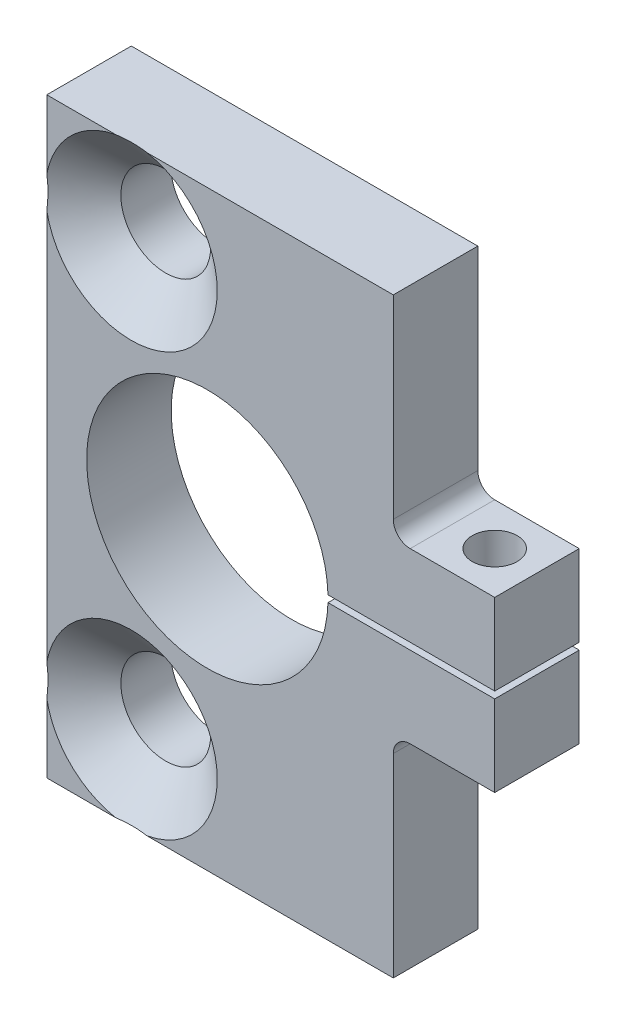
from build123d import *

# Parameters (mm, degrees)
SKETCH1_W                                           = 67.31
SKETCH1_H                                           = 88.9
EXTRUDE1_DEPTH                                      = 12.7
SKETCH2_R                                           = 18.1356
EXTRUDE2_DEPTH                                      = 13.7
SKETCH3_W                                           = 28.468633454
SKETCH3_H                                           = 1.016
EXTRUDE3_DEPTH                                      = 13.7
F_1_4_CLEARANCE_HOLE1_D                             = 6.7564
CSK_FOR_1_2_FLAT_HEAD_MACHINE_SCREW_100_D           = 13.49248
CSK_FOR_1_2_FLAT_HEAD_MACHINE_SCREW_100_CSINK_D     = 25.8318
CSK_FOR_1_2_FLAT_HEAD_MACHINE_SCREW_100_CSINK_ANGLE = 100
SKETCH10_W                                          = 15.24
SKETCH10_H                                          = 31.75
EXTRUDE4_DEPTH                                      = 13.7
FILLET1_R                                           = 2.54
FILLET1_OF_MIRROR2_R                                = 2.54


with BuildPart() as part:
    # Sketch1 → Extrude1 (new body)
    with BuildSketch(Plane.XY):
        Rectangle(SKETCH1_W, SKETCH1_H)
    extrude(amount=EXTRUDE1_DEPTH)

    # Sketch2 → Extrude2 (cut, through all)
    with BuildSketch(Plane.XY.offset(12.7)):
        with Locations((-9.525, 0)):
            Circle(SKETCH2_R)
    extrude(amount=-EXTRUDE2_DEPTH, mode=Mode.SUBTRACT)

    # Sketch3 → Extrude3 (cut, through all)
    with BuildSketch(Plane.XY.offset(12.7)):
        with Locations((21.1328, 0)):
            Rectangle(SKETCH3_W, SKETCH3_H)
    extrude(amount=-EXTRUDE3_DEPTH, mode=Mode.SUBTRACT)

    # 1/4 Clearance Hole1 (through all)
    with Locations(Plane(origin=(27.305, 44.45, 6.35), x_dir=(0, 0, 1), z_dir=(0, 1, 0))):
        with Locations((0, 0)):
            Hole(F_1_4_CLEARANCE_HOLE1_D / 2)

    # CSK for 1/2 Flat Head Machine Screw (100)1 (through all)
    with Locations(Plane(origin=(-20.955, 31.75, 12.7), x_dir=(1, 0, 0), z_dir=(0, 0, 1))):
        with Locations((0, 0)):
            csk_for_1_2_flat_head_machine_screw_100 = CounterSinkHole(CSK_FOR_1_2_FLAT_HEAD_MACHINE_SCREW_100_D / 2, CSK_FOR_1_2_FLAT_HEAD_MACHINE_SCREW_100_CSINK_D / 2, counter_sink_angle=CSK_FOR_1_2_FLAT_HEAD_MACHINE_SCREW_100_CSINK_ANGLE)

    # Mirror1: CSK for 1/2 Flat Head Machine Screw (100)1 across plane
    add(csk_for_1_2_flat_head_machine_screw_100.mirror(Plane.ZX), mode=Mode.SUBTRACT)

    # Sketch10 → Extrude4 (cut, through all)
    with BuildSketch(Plane.XY.offset(12.7)):
        with Locations((26.035, 28.575)):
            Rectangle(SKETCH10_W, SKETCH10_H)
    extrude4 = extrude(amount=-EXTRUDE4_DEPTH, mode=Mode.SUBTRACT)

    # Fillet1
    fillet1_edges = [part.edges().sort_by_distance(p)[0] for p in [
        (18.415, 12.7, 6.35),
    ]]
    fillet(fillet1_edges, radius=FILLET1_R)

    # Mirror2: Extrude4 across plane
    add(extrude4.mirror(Plane.ZX), mode=Mode.SUBTRACT)

    # Fillet1 of Mirror2
    fillet1_of_mirror2_edges = [part.edges().sort_by_distance(p)[0] for p in [
        (18.415, -12.7, 6.35),
    ]]
    fillet(fillet1_of_mirror2_edges, radius=FILLET1_OF_MIRROR2_R)


solid = part.part
